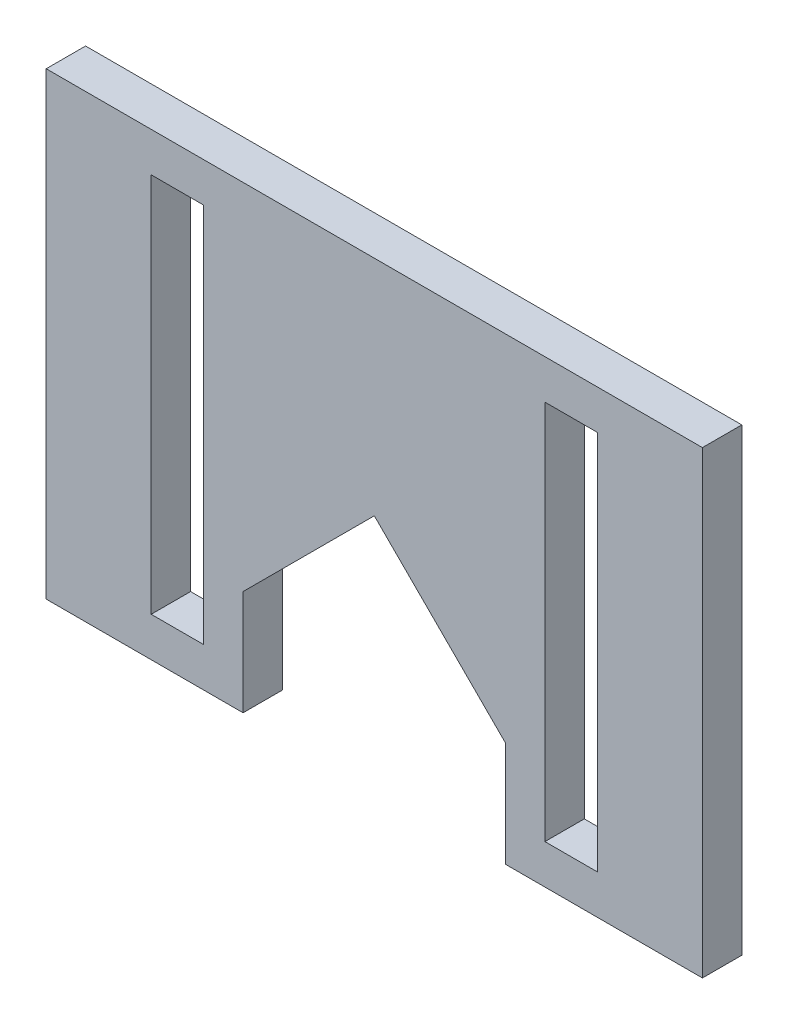
from build123d import *

# Parameters (mm, degrees)
ESQUISSE1_W        = 4
ESQUISSE1_H        = 29
BOSS_EXTRU_2_DEPTH = 3


with BuildPart() as part:
    # Esquisse1 → Boss.-Extru.2 (new body)
    with BuildSketch(Plane.XY):
        Polygon((-35, 0), (-35, 8), (-25, 18), (-15, 8), (-15, 0), (0, 0), (0, 35), (-50, 35), (-50, 0), align=None)
        with Locations((-10, 17.5)):
            Rectangle(ESQUISSE1_W, ESQUISSE1_H, mode=Mode.SUBTRACT)
        with Locations((-40, 17.5)):
            Rectangle(ESQUISSE1_W, ESQUISSE1_H, mode=Mode.SUBTRACT)
    extrude(amount=BOSS_EXTRU_2_DEPTH)


solid = part.part
